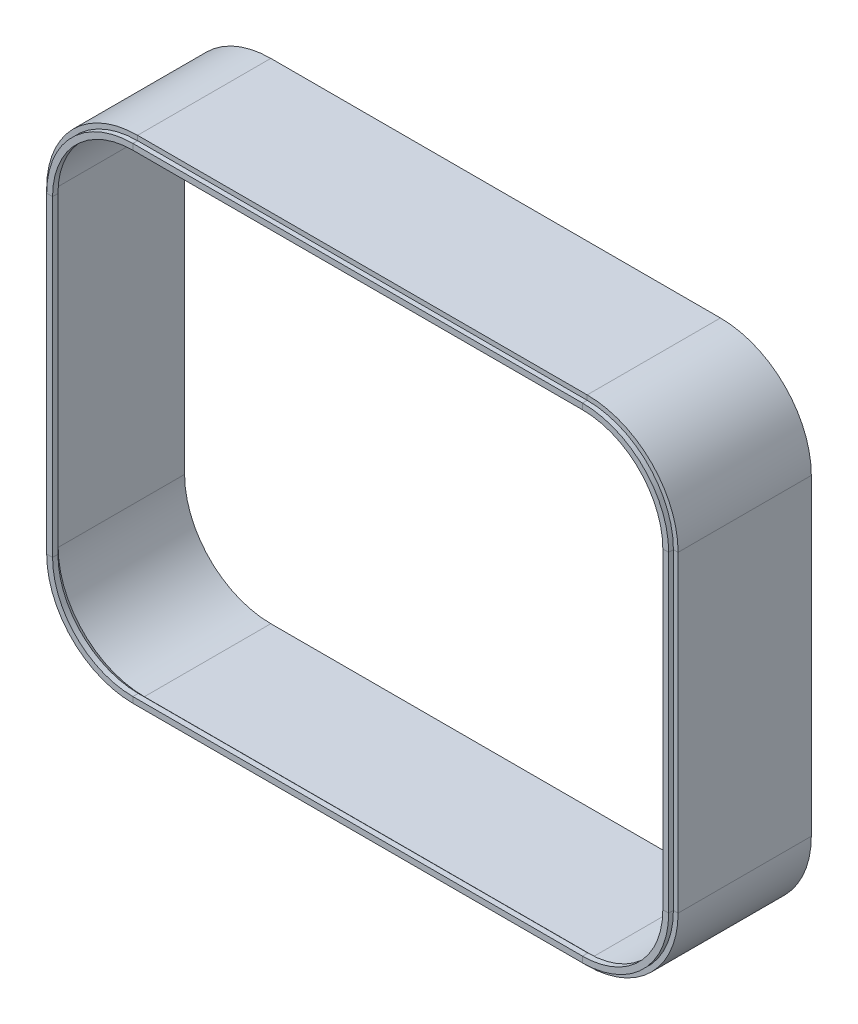
from build123d import *


with BuildPart() as part:
    # Sweep2: sweep along a path in BasketRing
    with BuildLine(Plane.XY) as sweep2_path:
        Line((44, 0), (273.5, 0))
        ThreePointArc((273.5, 0), (304.612698372, 12.887301628), (317.5, 44))
        Line((317.5, 44), (317.5, 203.5))
        ThreePointArc((317.5, 203.5), (304.612698372, 234.612698372), (273.5, 247.5))
        Line((273.5, 247.5), (44, 247.5))
        ThreePointArc((44, 247.5), (12.887301628, 234.612698372), (0, 203.5))
        Line((0, 203.5), (0, 44))
        ThreePointArc((0, 44), (12.887301628, 12.887301628), (44, 0))
    # ShapeOf Edge → Sweep2 (sweep)
    with BuildSketch(Plane(origin=(44, 0, 0), x_dir=(0, 0, -1), z_dir=(1, 0, 0))):
        Polygon((0, 0), (2.4, 0), (2.4, -2.4), (70.4, -2.4), (70.4, 0), (5.854935695, 0), (2.748344754, 3), (0, 3), align=None)
    sweep(path=sweep2_path.line)


solid = part.part
